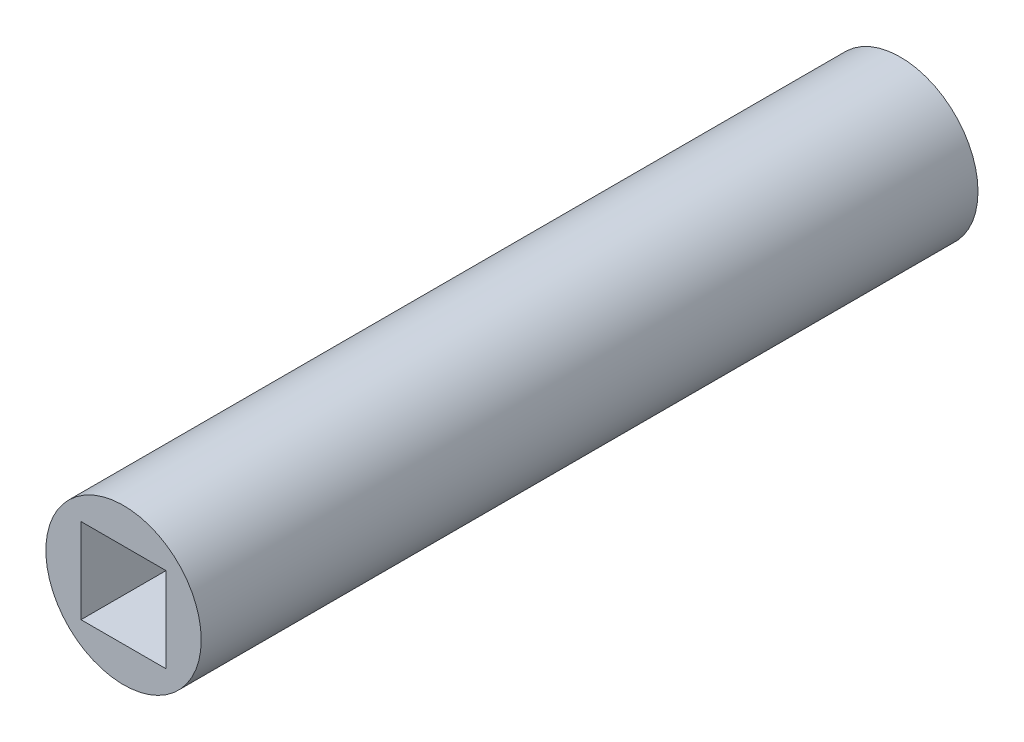
from build123d import *

# Parameters (mm, degrees)
SKETCH1_R           = 3.175
SKETCH1_W           = 3.475
SKETCH1_H           = 3.475
BOSS_EXTRUDE1_DEPTH = 31.75


with BuildPart() as part:
    # Sketch1 → Boss-Extrude1 (new body)
    with BuildSketch(Plane.XY):
        Circle(SKETCH1_R)
        Rectangle(SKETCH1_W, SKETCH1_H, mode=Mode.SUBTRACT)
    extrude(amount=BOSS_EXTRUDE1_DEPTH)


solid = part.part
